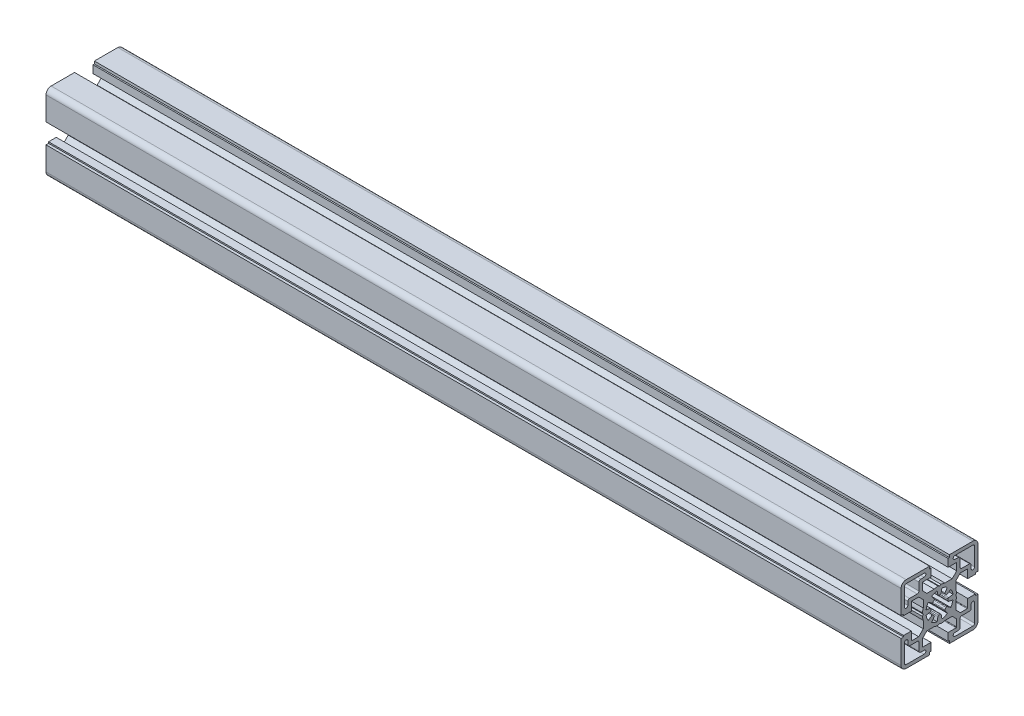
from build123d import *

# Parameters (mm, degrees)
EXTRUDE_1_DEPTH     = 500
CUT_EXTRUDE_1_DEPTH = 501


with BuildPart() as part:
    # Эскиз2 → Бобышка-Вытянуть1 (new body)
    with BuildSketch(Plane(origin=(0, 0, 0), x_dir=(0, 0, -1), z_dir=(1, 0, 0))):
        with BuildLine():
            Line((16.5, 5), (21, 5))
            Line((21, 5), (21, 5.799999))
            Line((21, 5.799999), (22.5, 5.799999))
            Line((22.5, 5.799999), (22.5, 19.5))
            ThreePointArc((22.5, 19.5), (21.621320344, 21.621320344), (19.5, 22.5))
            Line((19.5, 22.5), (5.799999, 22.5))
            Line((5.799999, 22.5), (5.799999, 21))
            Line((5.799999, 21), (5, 21))
            Line((5, 21), (5, 16.5))
            Line((5, 16.5), (9.75, 16.5))
            ThreePointArc((9.75, 16.5), (9.962132034, 16.412132034), (10.05, 16.2))
            Line((10.05, 16.2), (10.05, 12.171320344))
            Line((10.05, 12.171320344), (7.378679656, 9.5))
            Line((7.378679656, 9.5), (3.122498999, 9.5))
            ThreePointArc((3.122498999, 9.5), (2.007620973, 9.796400259), (0.866025404, 9.962429423))
            Line((0.866025404, 9.962429423), (0, 9.462429423))
            Line((0, 9.462429423), (-0.866025404, 9.962429423))
            ThreePointArc((-0.866025404, 9.962429423), (-2.007620973, 9.796400259), (-3.122498999, 9.5))
            Line((-3.122498999, 9.5), (-7.378679656, 9.5))
            Line((-7.378679656, 9.5), (-10.049999, 12.171319344))
            Line((-10.049999, 12.171319344), (-10.049999, 16.2))
            ThreePointArc((-10.049999, 16.2), (-9.962131034, 16.412132034), (-9.749999, 16.5))
            Line((-9.749999, 16.5), (-5, 16.5))
            Line((-5, 16.5), (-5, 21))
            Line((-5, 21), (-5.799999, 21))
            Line((-5.799999, 21), (-5.799999, 22.5))
            Line((-5.799999, 22.5), (-19.5, 22.5))
            ThreePointArc((-19.5, 22.5), (-21.621320344, 21.621320344), (-22.5, 19.5))
            Line((-22.5, 19.5), (-22.5, 5.799999))
            Line((-22.5, 5.799999), (-21, 5.799999))
            Line((-21, 5.799999), (-21, 5))
            Line((-21, 5), (-16.5, 5))
            Line((-16.5, 5), (-16.5, 9.749999))
            ThreePointArc((-16.5, 9.749999), (-16.412132034, 9.962131034), (-16.2, 10.049999))
            Line((-16.2, 10.049999), (-12.171319344, 10.049999))
            Line((-12.171319344, 10.049999), (-9.5, 7.378679656))
            Line((-9.5, 7.378679656), (-9.5, 3.122498999))
            ThreePointArc((-9.5, 3.122498999), (-9.796400259, 2.007620973), (-9.962429423, 0.866025404))
            Line((-9.962429423, 0.866025404), (-9.462429423, 0))
            Line((-9.462429423, 0), (-9.962429423, -0.866025404))
            ThreePointArc((-9.962429423, -0.866025404), (-9.796400259, -2.007620973), (-9.5, -3.122498999))
            Line((-9.5, -3.122498999), (-9.5, -7.378679656))
            Line((-9.5, -7.378679656), (-12.171320344, -10.05))
            Line((-12.171320344, -10.05), (-16.2, -10.05))
            ThreePointArc((-16.2, -10.05), (-16.412132034, -9.962132034), (-16.5, -9.75))
            Line((-16.5, -9.75), (-16.5, -5))
            Line((-16.5, -5), (-21, -5))
            Line((-21, -5), (-21, -5.799999))
            Line((-21, -5.799999), (-22.5, -5.799999))
            Line((-22.5, -5.799999), (-22.5, -19.5))
            ThreePointArc((-22.5, -19.5), (-21.621320344, -21.621320344), (-19.5, -22.5))
            Line((-19.5, -22.5), (-5.799999, -22.5))
            Line((-5.799999, -22.5), (-5.799999, -21))
            Line((-5.799999, -21), (-5, -21))
            Line((-5, -21), (-5, -16.5))
            Line((-5, -16.5), (-9.749999, -16.5))
            ThreePointArc((-9.749999, -16.5), (-9.962131034, -16.412132034), (-10.049999, -16.2))
            Line((-10.049999, -16.2), (-10.049999, -12.171319344))
            Line((-10.049999, -12.171319344), (-7.378679656, -9.5))
            Line((-7.378679656, -9.5), (-3.122498999, -9.5))
            ThreePointArc((-3.122498999, -9.5), (-2.007620973, -9.796400259), (-0.866025404, -9.962429423))
            Line((-0.866025404, -9.962429423), (0, -9.462429423))
            Line((0, -9.462429423), (0.866025404, -9.962429423))
            ThreePointArc((0.866025404, -9.962429423), (2.007620973, -9.796400259), (3.122498999, -9.5))
            Line((3.122498999, -9.5), (7.378679656, -9.5))
            Line((7.378679656, -9.5), (10.05, -12.171320344))
            Line((10.05, -12.171320344), (10.05, -16.2))
            ThreePointArc((10.05, -16.2), (9.962132034, -16.412132034), (9.75, -16.5))
            Line((9.75, -16.5), (5, -16.5))
            Line((5, -16.5), (5, -21))
            Line((5, -21), (5.799999, -21))
            Line((5.799999, -21), (5.799999, -22.5))
            Line((5.799999, -22.5), (19.5, -22.5))
            ThreePointArc((19.5, -22.5), (21.621320344, -21.621320344), (22.5, -19.5))
            Line((22.5, -19.5), (22.5, -5.799999))
            Line((22.5, -5.799999), (21, -5.799999))
            Line((21, -5.799999), (21, -5))
            Line((21, -5), (16.5, -5))
            Line((16.5, -5), (16.5, -9.75))
            ThreePointArc((16.5, -9.75), (16.412132034, -9.962132034), (16.2, -10.05))
            Line((16.2, -10.05), (12.171320344, -10.05))
            Line((12.171320344, -10.05), (9.5, -7.378679656))
            Line((9.5, -7.378679656), (9.5, -3.122498999))
            ThreePointArc((9.5, -3.122498999), (9.796400259, -2.007620973), (9.962429423, -0.866025404))
            Line((9.962429423, -0.866025404), (9.462429423, 0))
            Line((9.462429423, 0), (9.962429423, 0.866025404))
            ThreePointArc((9.962429423, 0.866025404), (9.796400259, 2.007620973), (9.5, 3.122498999))
            Line((9.5, 3.122498999), (9.5, 7.378679656))
            Line((9.5, 7.378679656), (12.171319344, 10.049999))
            Line((12.171319344, 10.049999), (16.2, 10.049999))
            ThreePointArc((16.2, 10.049999), (16.412132034, 9.962131034), (16.5, 9.749999))
            Line((16.5, 9.749999), (16.5, 5))
        make_face()
    extrude(amount=EXTRUDE_1_DEPTH)

    # Эскиз3 → Вырез-Вытянуть1 (cut, through all)
    with BuildSketch(Plane.ZY):
        with BuildLine():
            Line((-0.951109584, 5.394014463), (-1.38918508, 7.878462452))
            ThreePointArc((-1.38918508, 7.878462452), (-3.061467429, 7.391036664), (-4.588611737, 6.553216624))
            Line((-4.588611737, 6.553216624), (-3.14160736, 4.486680308))
            ThreePointArc((-3.14160736, 4.486680308), (-3.055338858, 4.135563126), (-3.228348507, 3.81808369))
            ThreePointArc((-3.228348507, 3.81808369), (-3.535533704, 3.535533704), (-3.81808369, 3.228348507))
            ThreePointArc((-3.81808369, 3.228348507), (-4.135563126, 3.055338858), (-4.486680308, 3.14160736))
            Line((-4.486680308, 3.14160736), (-6.553216624, 4.588611737))
            ThreePointArc((-6.553216624, 4.588611737), (-7.391036664, 3.061467429), (-7.878462452, 1.38918508))
            Line((-7.878462452, 1.38918508), (-5.394014463, 0.951109584))
            ThreePointArc((-5.394014463, 0.951109584), (-5.084736142, 0.763833295), (-4.982580573, 0.417005199))
            ThreePointArc((-4.982580573, 0.417005199), (-5.000000251, 0), (-4.982580573, -0.417005199))
            ThreePointArc((-4.982580573, -0.417005199), (-5.084736142, -0.763833295), (-5.394014463, -0.951109584))
            Line((-5.394014463, -0.951109584), (-7.878461766, -1.389184959))
            ThreePointArc((-7.878461766, -1.389184959), (-7.391036076, -3.06146703), (-6.553216219, -4.588611102))
            Line((-6.553216219, -4.588611102), (-4.486680308, -3.14160736))
            ThreePointArc((-4.486680308, -3.14160736), (-4.135563126, -3.055338858), (-3.81808369, -3.228348507))
            ThreePointArc((-3.81808369, -3.228348507), (-3.535533733, -3.535533675), (-3.22834857, -3.818083636))
            ThreePointArc((-3.22834857, -3.818083636), (-3.055338921, -4.135563118), (-3.141607485, -4.486680327))
            Line((-3.141607485, -4.486680327), (-4.588611972, -6.55321596))
            ThreePointArc((-4.588611972, -6.55321596), (-3.061467529, -7.39103618), (-1.38918499, -7.878462052))
            Line((-1.38918499, -7.878462052), (-0.951109584, -5.394014463))
            ThreePointArc((-0.951109584, -5.394014463), (-0.763833295, -5.084736142), (-0.417005199, -4.982580573))
            ThreePointArc((-0.417005199, -4.982580573), (0, -5.000000251), (0.417005199, -4.982580573))
            ThreePointArc((0.417005199, -4.982580573), (0.763833295, -5.084736142), (0.951109584, -5.394014463))
            Line((0.951109584, -5.394014463), (1.389184959, -7.878461766))
            ThreePointArc((1.389184959, -7.878461766), (3.061467283, -7.391035971), (4.58861155, -6.553215905))
            Line((4.58861155, -6.553215905), (3.141607485, -4.486680327))
            ThreePointArc((3.141607485, -4.486680327), (3.055338921, -4.135563118), (3.22834857, -3.818083636))
            ThreePointArc((3.22834857, -3.818083636), (3.535533704, -3.535533704), (3.818083636, -3.22834857))
            ThreePointArc((3.818083636, -3.22834857), (4.135563118, -3.055338921), (4.486680327, -3.141607485))
            Line((4.486680327, -3.141607485), (6.55321596, -4.588611972))
            ThreePointArc((6.55321596, -4.588611972), (7.39103618, -3.061467529), (7.878462052, -1.38918499))
            Line((7.878462052, -1.38918499), (5.394014463, -0.951109584))
            ThreePointArc((5.394014463, -0.951109584), (5.084736142, -0.763833295), (4.982580573, -0.417005199))
            ThreePointArc((4.982580573, -0.417005199), (5.000000251, 0), (4.982580573, 0.417005199))
            ThreePointArc((4.982580573, 0.417005199), (5.084736142, 0.763833295), (5.394014463, 0.951109584))
            Line((5.394014463, 0.951109584), (7.878462049, 1.389185009))
            ThreePointArc((7.878462049, 1.389185009), (7.391036176, 3.061467538), (6.55321596, 4.588611972))
            Line((6.55321596, 4.588611972), (4.486680327, 3.141607485))
            ThreePointArc((4.486680327, 3.141607485), (4.135563118, 3.055338921), (3.818083636, 3.22834857))
            ThreePointArc((3.818083636, 3.22834857), (3.535533675, 3.535533733), (3.228348507, 3.81808369))
            ThreePointArc((3.228348507, 3.81808369), (3.055338858, 4.135563126), (3.14160736, 4.486680308))
            Line((3.14160736, 4.486680308), (4.588611737, 6.553216624))
            ThreePointArc((4.588611737, 6.553216624), (3.061467429, 7.391036664), (1.38918508, 7.878462452))
            Line((1.38918508, 7.878462452), (0.951109584, 5.394014463))
            ThreePointArc((0.951109584, 5.394014463), (0.763833295, 5.084736142), (0.417005199, 4.982580573))
            ThreePointArc((0.417005199, 4.982580573), (0, 5.000000251), (-0.417005199, 4.982580573))
            ThreePointArc((-0.417005199, 4.982580573), (-0.763833295, 5.084736142), (-0.951109584, 5.394014463))
        make_face()
        with BuildLine():
            Line((-17.5, 12), (-13, 12))
            ThreePointArc((-13, 12), (-12.292894344, 12.292894094), (-12.000002, 13.000000474))
            Line((-12.000002, 13.000000474), (-12, 17.5))
            ThreePointArc((-12, 17.5), (-11.707106781, 18.207106781), (-11, 18.5))
            Line((-11, 18.5), (-9, 18.5))
            ThreePointArc((-9, 18.5), (-8, 19.5), (-9, 20.5))
            Line((-9, 20.5), (-19.5, 20.5))
            ThreePointArc((-19.5, 20.5), (-20.207106781, 20.207106781), (-20.5, 19.5))
            Line((-20.5, 19.5), (-20.5, 9))
            ThreePointArc((-20.5, 9), (-19.5, 8), (-18.5, 9))
            Line((-18.5, 9), (-18.5, 11))
            ThreePointArc((-18.5, 11), (-18.207106781, 11.707106781), (-17.5, 12))
        make_face()
        with BuildLine():
            Line((17.5, 12), (13.000000474, 12.000002))
            ThreePointArc((13.000000474, 12.000002), (12.292894094, 12.292894344), (12, 13))
            Line((12, 13), (12, 17.5))
            ThreePointArc((12, 17.5), (11.707106781, 18.207106781), (11, 18.5))
            Line((11, 18.5), (9, 18.5))
            ThreePointArc((9, 18.5), (8, 19.5), (9, 20.5))
            Line((9, 20.5), (19.5, 20.5))
            ThreePointArc((19.5, 20.5), (20.207106781, 20.207106781), (20.5, 19.5))
            Line((20.5, 19.5), (20.5, 9))
            ThreePointArc((20.5, 9), (19.5, 8), (18.5, 9))
            Line((18.5, 9), (18.5, 11))
            ThreePointArc((18.5, 11), (18.207106781, 11.707106781), (17.5, 12))
        make_face()
        with BuildLine():
            Line((-17.5, -12), (-13.000000474, -12.000002))
            ThreePointArc((-13.000000474, -12.000002), (-12.292894094, -12.292894344), (-12, -13))
            Line((-12, -13), (-12, -17.5))
            ThreePointArc((-12, -17.5), (-11.707106781, -18.207106781), (-11, -18.5))
            Line((-11, -18.5), (-9, -18.5))
            ThreePointArc((-9, -18.5), (-8, -19.5), (-9, -20.5))
            Line((-9, -20.5), (-19.5, -20.5))
            ThreePointArc((-19.5, -20.5), (-20.207106781, -20.207106781), (-20.5, -19.5))
            Line((-20.5, -19.5), (-20.5, -9))
            ThreePointArc((-20.5, -9), (-19.5, -8), (-18.5, -9))
            Line((-18.5, -9), (-18.5, -11))
            ThreePointArc((-18.5, -11), (-18.207106781, -11.707106781), (-17.5, -12))
        make_face()
        with BuildLine():
            Line((19.5, -20.5), (9, -20.5))
            ThreePointArc((9, -20.5), (8, -19.5), (9, -18.5))
            Line((9, -18.5), (11, -18.5))
            ThreePointArc((11, -18.5), (11.707106781, -18.207106781), (12, -17.5))
            Line((12, -17.5), (12.000002, -13.000000474))
            ThreePointArc((12.000002, -13.000000474), (12.292894344, -12.292894094), (13, -12))
            Line((13, -12), (17.5, -12))
            ThreePointArc((17.5, -12), (18.207106781, -11.707106781), (18.5, -11))
            Line((18.5, -11), (18.5, -9))
            ThreePointArc((18.5, -9), (19.5, -8), (20.5, -9))
            Line((20.5, -9), (20.5, -19.5))
            ThreePointArc((20.5, -19.5), (20.207106781, -20.207106781), (19.5, -20.5))
        make_face()
    extrude(amount=-CUT_EXTRUDE_1_DEPTH, mode=Mode.SUBTRACT)


solid = part.part
